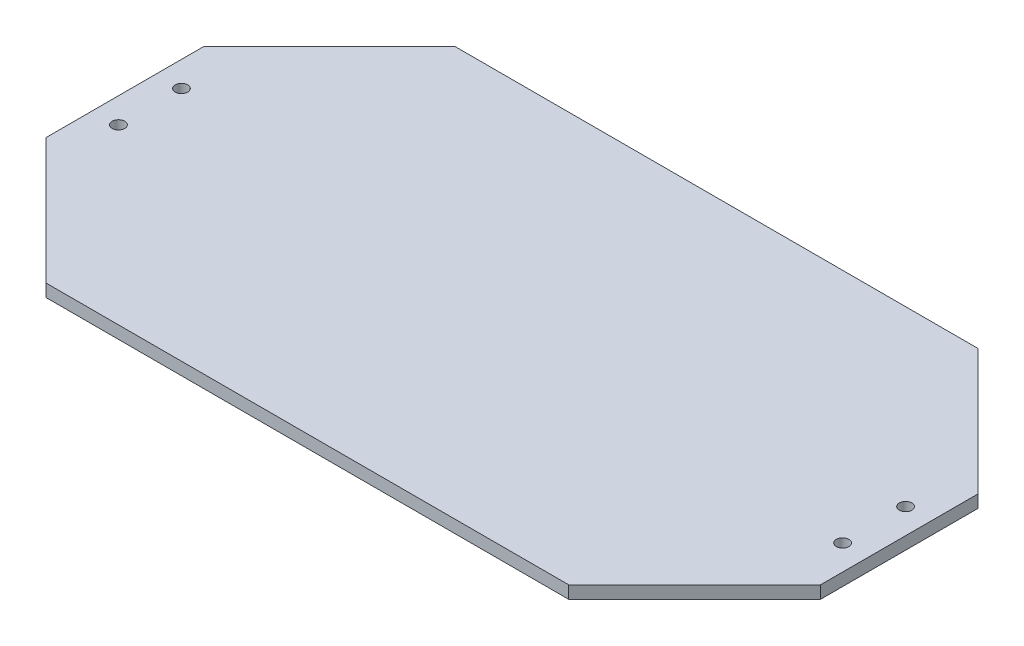
from build123d import *

# Parameters (mm, degrees)
SKETCH1_R           = 2.54
BOSS_EXTRUDE1_DEPTH = 5.08


with BuildPart() as part:
    # Sketch1 → Boss-Extrude1 (new body)
    with BuildSketch(Plane(origin=(0, 0, 0), x_dir=(1, 0, 0), z_dir=(0, 1, 0))):
        Polygon((-10.16, 31.75), (-10.16, -31.75), (40.64, -82.55), (251.46, -82.55), (302.26, -31.75), (302.26, 31.75), (251.46, 82.55), (40.64, 82.55), align=None)
        with Locations((0, -12.7)):
            Circle(SKETCH1_R, mode=Mode.SUBTRACT)
        with Locations((292.1, -12.7)):
            Circle(SKETCH1_R, mode=Mode.SUBTRACT)
        with Locations((0, 12.7)):
            Circle(SKETCH1_R, mode=Mode.SUBTRACT)
        with Locations((292.1, 12.7)):
            Circle(SKETCH1_R, mode=Mode.SUBTRACT)
    extrude(amount=BOSS_EXTRUDE1_DEPTH)


solid = part.part
